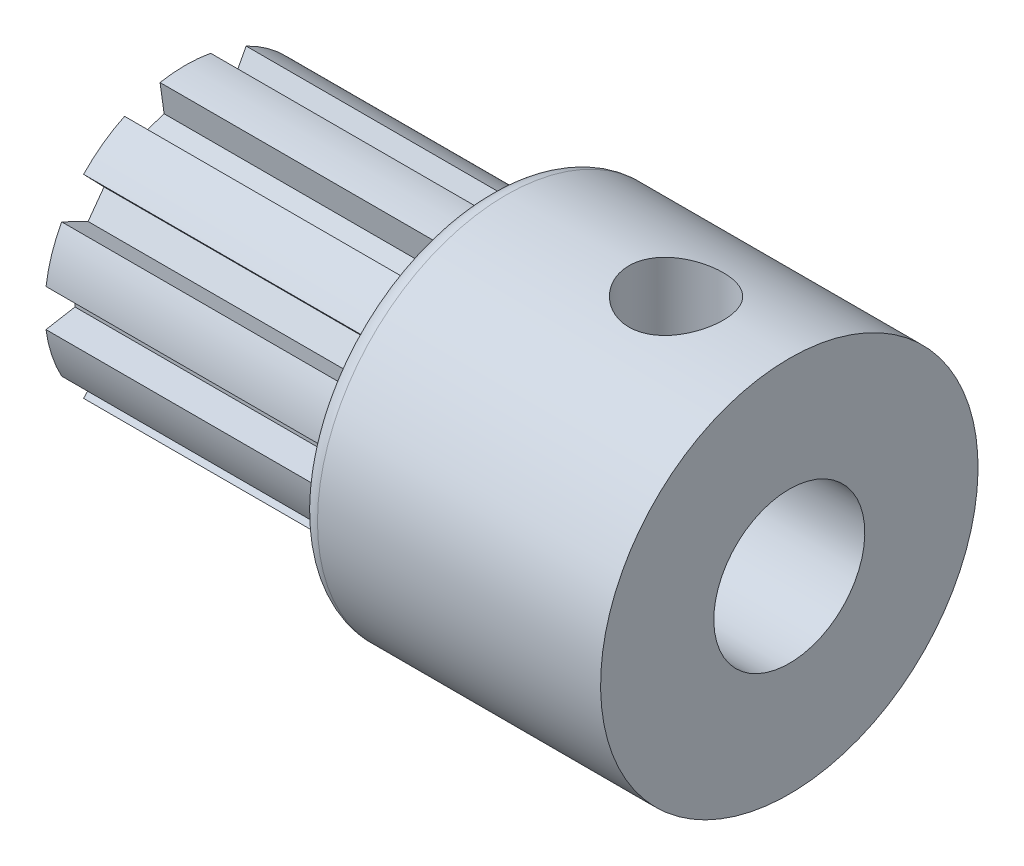
from build123d import *

# Parameters (mm, degrees)
ESQUISSE2_R                  = 2
ENL_V_MAT_EXTRU_1_DEPTH      = 17
CONG_1_R                     = 0.5
ENL_V_MAT_EXTRU_2_DEPTH      = 8
R_P_TITION_CIRCULAIRE1_COUNT = 10
ESQUISSE4_W                  = 1.25
ESQUISSE4_H                  = 5


with BuildPart() as part:
    # Esquisse1 → Révolution1 (revolve)
    with BuildSketch(Plane.XY):
        Polygon((0, 0), (0, 3.725), (8, 3.725), (8, 5), (16, 5), (16, 0), align=None)
    revolve(axis=Axis((16, 0, 0), (-1, 0, 0)))

    # Esquisse2 → Enlèv. mat.-Extru.1 (cut, through all)
    with BuildSketch(Plane(origin=(16, 0, 0), x_dir=(0, 0, -1), z_dir=(1, 0, 0))):
        with Locations(Location((0, 0, 0), (0, 0, 90))):  # turned: the seam where the file's is
            Circle(ESQUISSE2_R)
    extrude(amount=-ENL_V_MAT_EXTRU_1_DEPTH, mode=Mode.SUBTRACT)

    # Congé1
    cong_1_edges = [part.edges().sort_by_distance(p)[0] for p in [
        (8, -5, 0),
    ]]
    fillet(cong_1_edges, radius=CONG_1_R)

    # Esquisse3 → Enlèv. mat.-Extru.2 (cut)
    with BuildSketch(Plane.ZY):
        Polygon((0.675560046, 3.69719402), (0.56250399, 2.89275838), (1.245245427, 2.67092224), (1.626616562, 3.388177026), align=None)
    enl_v_mat_extru_2 = extrude(amount=-ENL_V_MAT_EXTRU_2_DEPTH, mode=Mode.SUBTRACT)

    # Répétition circulaire1: Enlèv. mat.-Extru.2 ×10 about axis
    r_p_tition_circulaire1_axis = Axis((0, 0, 0), (1, 0, 0))
    for i in range(1, R_P_TITION_CIRCULAIRE1_COUNT):
        add(enl_v_mat_extru_2.rotate(r_p_tition_circulaire1_axis, i * 360 / R_P_TITION_CIRCULAIRE1_COUNT), mode=Mode.SUBTRACT)

    # Esquisse4 → Trou taraudé M31 (revolve, cut)
    with BuildSketch(Plane(origin=(13, 0, 0), x_dir=(0, 0, -1), z_dir=(1, 0, 0))):
        with Locations((0.625, 2.5)):
            Rectangle(ESQUISSE4_W, ESQUISSE4_H)
    revolve(axis=Axis((13, -6.35, 0), (0, 1, 0)), mode=Mode.SUBTRACT)


solid = part.part
